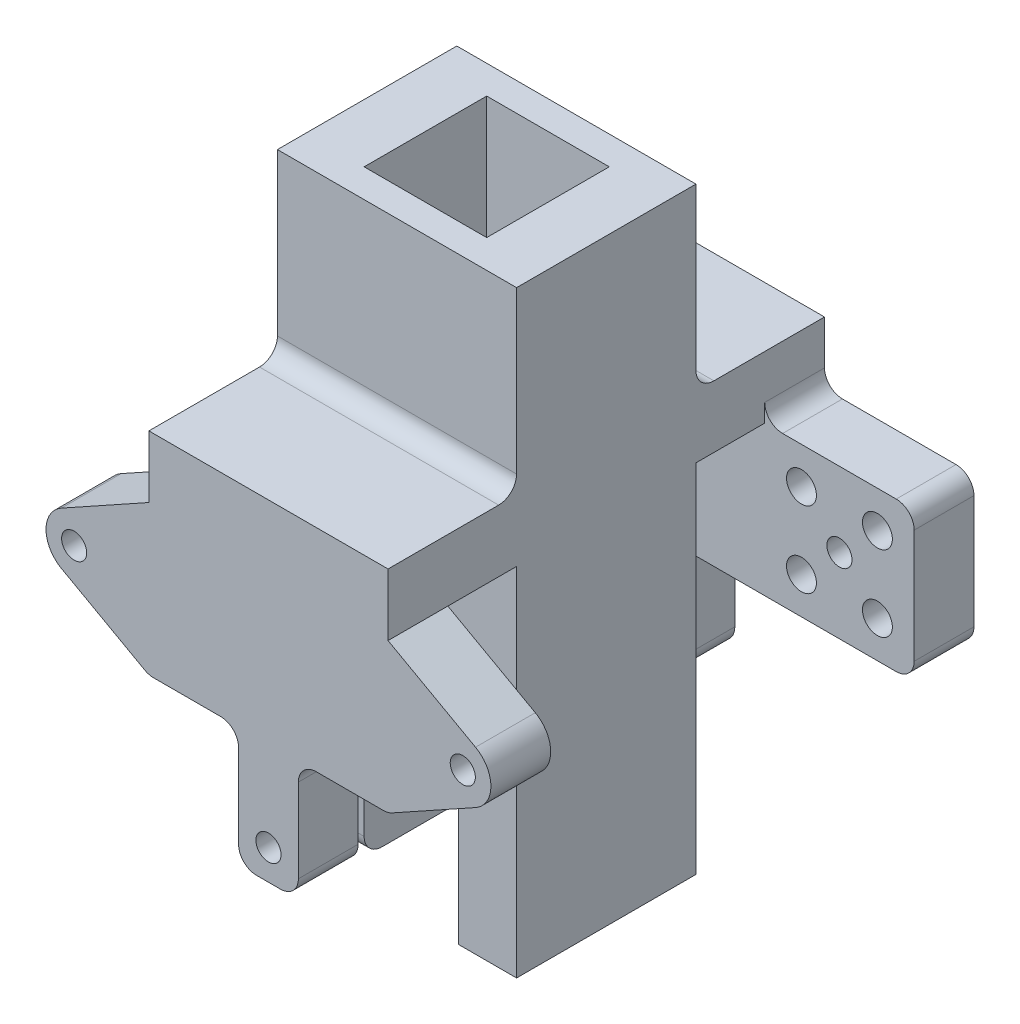
from build123d import *

# Parameters (mm, degrees)
SKETCH2_W           = 40
SKETCH2_H           = 30
BOSS_EXTRUDE1_DEPTH = 100
SKETCH3_W           = 20.5
SKETCH3_H           = 20.5
CUT_EXTRUDE1_DEPTH  = 100
SKETCH4_W           = 20.5
SKETCH4_H           = 50
CUT_EXTRUDE2_DEPTH  = 4.75
SKETCH5_W           = 4.75
SKETCH5_H           = 25
CUT_EXTRUDE4_DEPTH  = 9.75
SKETCH6_R           = 2.1
CUT_EXTRUDE5_DEPTH  = 9.75
SKETCH7_R           = 2.5
CUT_EXTRUDE6_DEPTH  = 5.18
SKETCH8_W           = 40
SKETCH8_H           = 10.38
BOSS_EXTRUDE2_DEPTH = 21.5
SKETCH9_W           = 40
SKETCH9_H           = 10
BOSS_EXTRUDE3_DEPTH = 45
BOSS_EXTRUDE4_START = -65
SKETCH11_W          = 10
SKETCH11_H          = 25
BOSS_EXTRUDE4_DEPTH = 90
SKETCH13_R          = 2.1
CUT_EXTRUDE7_DEPTH  = 4.57
SKETCH14_R          = 2.1
SKETCH14_R_2        = 2.5
CUT_EXTRUDE8_DEPTH  = 5.43
SKETCH15_R          = 2.1
CUT_EXTRUDE9_DEPTH  = 10
CUT_EXTRUDE10_REACH = 133.735
SKETCH18_R          = 2.1
SKETCH19_W          = 15
SKETCH19_H          = 20.005
CUT_EXTRUDE11_DEPTH = 12.57
FILLET1_R           = 3


with BuildPart() as part:
    # Sketch2 → Boss-Extrude1 (new body)
    with BuildSketch(Plane(origin=(0, 0, 0), x_dir=(1, 0, 0), z_dir=(0, 1, 0))):
        Rectangle(SKETCH2_W, SKETCH2_H)
    extrude(amount=BOSS_EXTRUDE1_DEPTH)

    # Sketch3 → Cut-Extrude1 (cut)
    with BuildSketch(Plane(origin=(0, 0, 0), x_dir=(1, 0, 0), z_dir=(0, 1, 0))):
        Rectangle(SKETCH3_W, SKETCH3_H)
    extrude(amount=CUT_EXTRUDE1_DEPTH, mode=Mode.SUBTRACT)

    # Sketch4 → Cut-Extrude2 (cut)
    with BuildSketch(Plane.XY.offset(15)):
        Rectangle(SKETCH4_W, SKETCH4_H)
    extrude(amount=-CUT_EXTRUDE2_DEPTH, mode=Mode.SUBTRACT)

    # Sketch5 → Cut-Extrude4 (cut)
    with BuildSketch(Plane(origin=(-10.25, 0, 0), x_dir=(0, 0, -1), z_dir=(1, 0, 0))):
        with Locations((-12.625, 12.5)):
            Rectangle(SKETCH5_W, SKETCH5_H)
    extrude(amount=-CUT_EXTRUDE4_DEPTH, mode=Mode.SUBTRACT)

    # Sketch6 → Cut-Extrude5 (cut)
    with BuildSketch(Plane.ZY.offset(20)):
        with Locations((2.425, 12.5)):
            Circle(SKETCH6_R)
        with Locations((-10.275, 12.5)):
            Circle(SKETCH6_R)
        with Locations((-3.925, 18.85)):
            Circle(SKETCH6_R)
        with Locations((-3.925, 6.15)):
            Circle(SKETCH6_R)
    extrude(amount=-CUT_EXTRUDE5_DEPTH, mode=Mode.SUBTRACT)

    # Sketch7 → Cut-Extrude6 (cut)
    with BuildSketch(Plane(origin=(-10.25, 0, 0), x_dir=(0, 0, -1), z_dir=(1, 0, 0))):
        with Locations((-2.425, 12.5)):
            Circle(SKETCH7_R)
        with Locations((10.275, 12.5)):
            Circle(SKETCH7_R)
        with Locations((3.925, 18.85)):
            Circle(SKETCH7_R)
        with Locations((3.925, 6.15)):
            Circle(SKETCH7_R)
    extrude(amount=-CUT_EXTRUDE6_DEPTH, mode=Mode.SUBTRACT)

    # Sketch8 → Boss-Extrude2 (add)
    with BuildSketch(Plane(origin=(0, 0, -15), x_dir=(-1, 0, 0), z_dir=(0, 0, -1))):
        with Locations((0, 64.81)):
            Rectangle(SKETCH8_W, SKETCH8_H)
    boss_extrude2 = extrude(amount=BOSS_EXTRUDE2_DEPTH)

    # Sketch9 → Boss-Extrude3 (add)
    with BuildSketch(Plane.XZ.offset(-59.62)):
        with Locations((0, -31.5)):
            Rectangle(SKETCH9_W, SKETCH9_H)
    boss_extrude3 = extrude(amount=BOSS_EXTRUDE3_DEPTH)

    # Sketch11 → Boss-Extrude4 (add)
    with BuildSketch(Plane(origin=(20, 0, 0), x_dir=(0, 0, -1), z_dir=(1, 0, 0)).offset(BOSS_EXTRUDE4_START)):
        with Locations((31.5, 47.125)):
            Rectangle(SKETCH11_W, SKETCH11_H)
    boss_extrude4 = extrude(amount=BOSS_EXTRUDE4_DEPTH)

    # Sketch13 → Cut-Extrude7 (cut)
    with BuildSketch(Plane(origin=(0, 0, -36.5), x_dir=(-1, 0, 0), z_dir=(0, 0, -1))):
        with Locations((-32.5, 47.125)):
            Circle(SKETCH13_R)
        with Locations((-26.15, 53.475)):
            Circle(SKETCH13_R)
        with Locations((-38.85, 53.475)):
            Circle(SKETCH13_R)
        with Locations((-38.85, 40.775)):
            Circle(SKETCH13_R)
        with Locations((-26.15, 40.775)):
            Circle(SKETCH13_R)
    extrude(amount=-CUT_EXTRUDE7_DEPTH, mode=Mode.SUBTRACT)

    # Sketch14 → Cut-Extrude8 (cut)
    with BuildSketch(Plane.XY.offset(-26.5)):
        with Locations(Location((32.5, 47.125, 0), (0, 0, 180))):
            Circle(SKETCH14_R)
        with Locations((38.85, 53.475)):
            Circle(SKETCH14_R_2)
        with Locations((26.15, 53.475)):
            Circle(SKETCH14_R_2)
        with Locations((26.15, 40.775)):
            Circle(SKETCH14_R_2)
        with Locations((38.85, 40.775)):
            Circle(SKETCH14_R_2)
    extrude(amount=-CUT_EXTRUDE8_DEPTH, mode=Mode.SUBTRACT)

    # Sketch15 → Cut-Extrude9 (cut)
    with BuildSketch(Plane(origin=(0, 0, -36.5), x_dir=(-1, 0, 0), z_dir=(0, 0, -1))):
        with Locations((32.5, 47.125)):
            Circle(SKETCH15_R)
        with Locations((0, 19.65)):
            Circle(SKETCH15_R)
        with BuildLine():
            Line((20, 59.625), (34.632584515, 51.495786381))
            ThreePointArc((34.632584515, 51.495786381), (37.204369859, 47.125), (34.632584515, 42.754213619))
            Line((34.632584515, 42.754213619), (20, 34.625))
            Line((20, 34.625), (45, 34.625))
            Line((45, 34.625), (45, 59.625))
            Line((45, 59.625), (20, 59.625))
        make_face()
    cut_extrude9 = extrude(amount=-CUT_EXTRUDE9_DEPTH, mode=Mode.SUBTRACT)

    # Mirror2: Boss-Extrude2, Boss-Extrude3, Boss-Extrude4, Cut-Extrude9 across plane
    add(boss_extrude2.mirror(Plane.XY))
    add(boss_extrude3.mirror(Plane.XY))
    add(boss_extrude4.mirror(Plane.XY))
    add(cut_extrude9.mirror(Plane.XY), mode=Mode.SUBTRACT)

    # Sketch18 → Cut-Extrude10 (cut, up to next)
    with BuildSketch(Plane.XY.offset(36.5), mode=Mode.PRIVATE) as cut_extrude10_sk1:
        with BuildLine():
            Line((20, 59.625), (34.632584515, 51.495786381))
            ThreePointArc((34.632584515, 51.495786381), (37.204369859, 47.125), (34.632584515, 42.754213619))
            Line((34.632584515, 42.754213619), (20, 34.625))
            Line((20, 34.625), (45, 34.625))
            Line((45, 34.625), (45, 59.625))
            Line((45, 59.625), (20, 59.625))
        make_face()
    cut_extrude10_tool1 = extrude(cut_extrude10_sk1.sketch, amount=-CUT_EXTRUDE10_REACH, mode=Mode.PRIVATE) & part.part
    # Sketch18 → Cut-Extrude10 (cut, up to next)
    with BuildSketch(Plane.XY.offset(36.5), mode=Mode.PRIVATE) as cut_extrude10_sk2:
        with Locations(Location((32.5, 47.125, 0), (0, 0, 180))):
            Circle(SKETCH18_R)
    cut_extrude10_tool2 = extrude(cut_extrude10_sk2.sketch, amount=-CUT_EXTRUDE10_REACH, mode=Mode.PRIVATE) & part.part
    add(cut_extrude10_tool1.solids().sort_by_distance((27.487993, 55.869454, 36.5))[0], mode=Mode.SUBTRACT)
    add(cut_extrude10_tool2.solids().sort_by_distance((32.5, 47.125, 36.5))[0], mode=Mode.SUBTRACT)

    # Sketch19 → Cut-Extrude11 (cut)
    with BuildSketch(Plane.XY.offset(36.5)):
        with Locations((-12.5, 24.6225)):
            Rectangle(SKETCH19_W, SKETCH19_H)
        with Locations((12.5, 24.6225)):
            Rectangle(SKETCH19_W, SKETCH19_H)
    cut_extrude11 = extrude(amount=-CUT_EXTRUDE11_DEPTH, mode=Mode.SUBTRACT)

    # Mirror3: Cut-Extrude11 across plane
    add(cut_extrude11.mirror(Plane.XY), mode=Mode.SUBTRACT)

    # Fillet1
    fillet1_edges = [part.edges().sort_by_distance(p)[0] for p in [
        (0, 70, -15),
        (20, 59.625, -31.5),
        (-20, 34.625, -31.5),
        (45, 34.625, -31.5),
        (45, 59.625, -31.5),
        (0, 70, 15),
        (20, 34.625, 31.5),
        (-20, 34.625, 31.5),
        (5, 14.62, 31.5),
        (-5, 14.62, 31.5),
        (-5, 34.625, 31.5),
        (5, 34.625, 31.5),
        (5, 14.62, -31.5),
        (-5, 14.62, -31.5),
        (-5, 34.625, -31.5),
        (5, 34.625, -31.5),
        (-15.125, 0, 10.25),
    ]]
    fillet(fillet1_edges, radius=FILLET1_R)


solid = part.part
